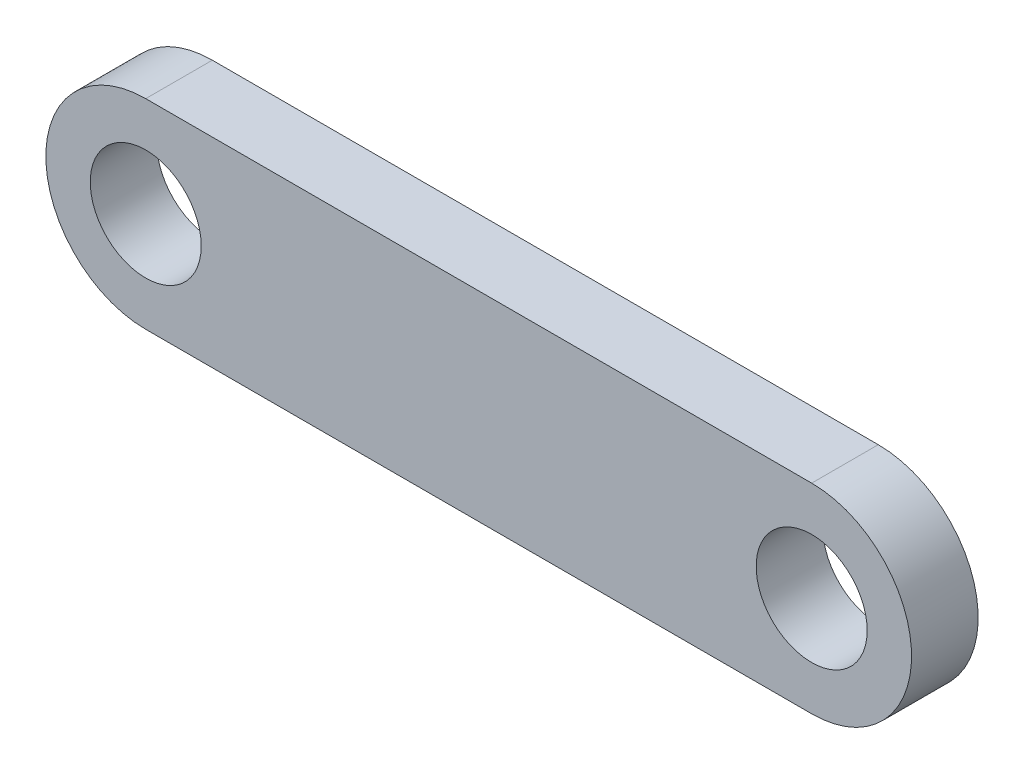
from build123d import *

# Parameters (mm, degrees)
CROQUIS1_R              = 5
SALIENTE_EXTRUIR1_DEPTH = 6


with BuildPart() as part:
    # Croquis1 → Saliente-Extruir1 (new body)
    with BuildSketch(Plane.XY):
        with BuildLine():
            Line((-22.679457404, 9), (37.320542596, 9))
            ThreePointArc((37.320542596, 9), (46.320542596, 0), (37.320542596, -9))
            Line((37.320542596, -9), (-22.679457404, -9))
            ThreePointArc((-22.679457404, -9), (-31.679457404, 0), (-22.679457404, 9))
        make_face()
        with Locations((-22.679457404, 0)):
            Circle(CROQUIS1_R, mode=Mode.SUBTRACT)
        with Locations((37.320542596, 0)):
            Circle(CROQUIS1_R, mode=Mode.SUBTRACT)
    extrude(amount=SALIENTE_EXTRUIR1_DEPTH)


solid = part.part
